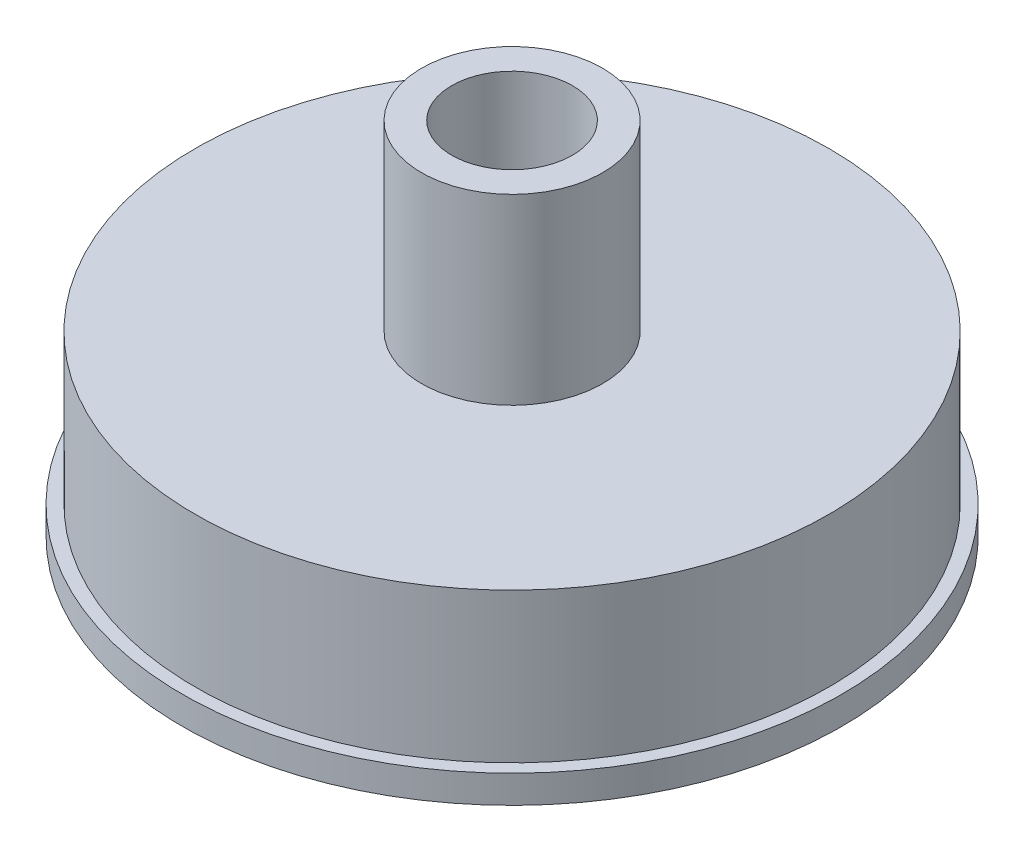
from build123d import *


with BuildPart() as part:
    # Sketch1 → Revolve1 (revolve)
    with BuildSketch(Plane.XY):
        Polygon((26, 2.2), (25, 2.2), (25, 14), (7.14375, 14), (7.14375, 28.4125), (4.7625, 28.4125), (4.7625, 11), (21, 11), (21, 0), (26, 0), align=None)
    revolve(axis=Axis((0, 0, 0), (0, 1, 0)))


solid = part.part
